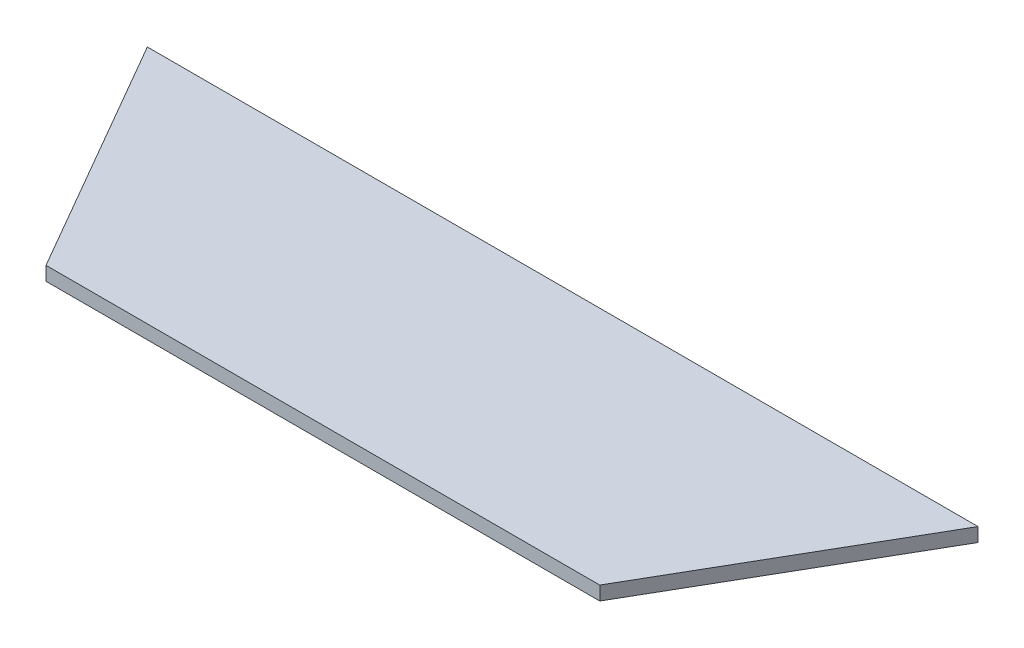
from build123d import *

# Parameters (mm, degrees)
BOSS_EXTRUDE1_DEPTH = 5


with BuildPart() as part:
    # Sketch1 → Boss-Extrude1 (new body)
    with BuildSketch(Plane(origin=(0, 0, 0), x_dir=(1, 0, 0), z_dir=(0, 1, 0))):
        Polygon((-150, -86.602540378), (-100, -173.205080757), (100, -173.205080757), (150, -86.602540378), align=None)
    extrude(amount=BOSS_EXTRUDE1_DEPTH)


solid = part.part
